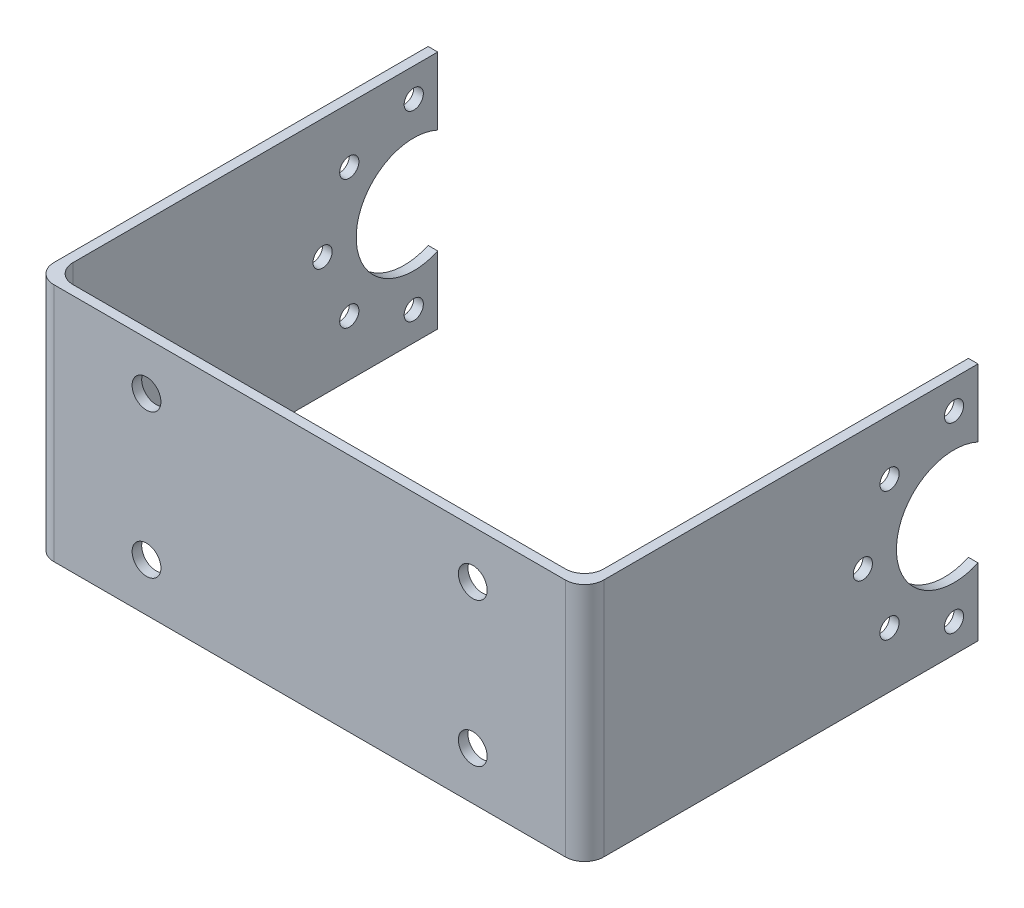
from build123d import *

# Parameters (mm, degrees)
BOSS_EXTRUDE1_DEPTH = 25
SKETCH2_R           = 1
SKETCH2_R_2         = 6
CUT_EXTRUDE1_DEPTH  = 58.3
FILLET2_R           = 2
SKETCH3_R           = 1.5
CUT_EXTRUDE2_DEPTH  = 42


with BuildPart() as part:
    # Sketch1 → Boss-Extrude1 (new body)
    with BuildSketch(Plane(origin=(0, 0, 0), x_dir=(1, 0, 0), z_dir=(0, 1, 0))):
        Polygon((-21.5, 0.5), (33.8, 0.5), (33.8, 40.5), (34.8, 40.5), (34.8, 0.5), (34.8, -0.5), (-22.5, -0.5), (-22.5, 0.5), (-22.5, 40.5), (-21.5, 40.5), align=None)
    extrude(amount=BOSS_EXTRUDE1_DEPTH)

    # Sketch2 → Cut-Extrude1 (cut, through all)
    with BuildSketch(Plane(origin=(34.8, 0, 0), x_dir=(0, 0, -1), z_dir=(1, 0, 0))):
        with Locations((28.5, 12.5)):
            Circle(SKETCH2_R)
        with Locations((38, 12.5)):
            Circle(SKETCH2_R_2)
        with Locations((31.282485579, 19.217514421)):
            Circle(SKETCH2_R)
        with Locations((38, 22)):
            Circle(SKETCH2_R)
        with Locations((38, 3)):
            Circle(SKETCH2_R)
        with Locations((31.282485579, 5.782485579)):
            Circle(SKETCH2_R)
    extrude(amount=-CUT_EXTRUDE1_DEPTH, mode=Mode.SUBTRACT)

    # Fillet2
    fillet2_edges = [part.edges().sort_by_distance(p)[0] for p in [
        (34.8, 12.5, 0.5),
        (-22.5, 12.5, 0.5),
        (-21.5, 12.5, -0.5),
        (33.8, 12.5, -0.5),
    ]]
    fillet(fillet2_edges, radius=FILLET2_R)

    # Sketch3 → Cut-Extrude2 (cut, through all)
    with BuildSketch(Plane.XY.offset(0.5)):
        with Locations((-10.85, 20)):
            Circle(SKETCH3_R)
        with Locations((23.15, 20)):
            Circle(SKETCH3_R)
        with Locations((-10.85, 5)):
            Circle(SKETCH3_R)
        with Locations((23.15, 5)):
            Circle(SKETCH3_R)
    extrude(amount=-CUT_EXTRUDE2_DEPTH, mode=Mode.SUBTRACT)


solid = part.part
